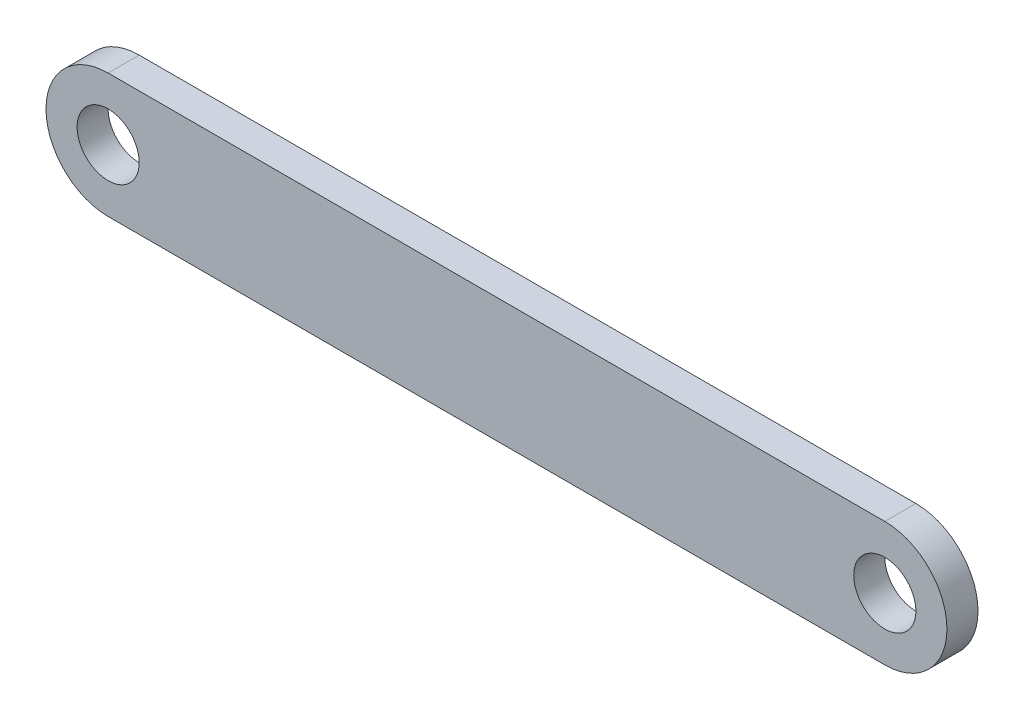
from build123d import *

# Parameters (mm, degrees)
SKETCH2_R           = 2
BOSS_EXTRUDE1_DEPTH = 2


with BuildPart() as part:
    # Sketch2 → Boss-Extrude1 (new body)
    with BuildSketch(Plane.XY):
        with BuildLine():
            Line((0, -4), (-50, -4))
            ThreePointArc((-50, -4), (-54, 0), (-50, 4))
            Line((-50, 4), (0, 4))
            ThreePointArc((0, 4), (4, 0), (0, -4))
        make_face()
        with Locations((-50, 0)):
            Circle(SKETCH2_R, mode=Mode.SUBTRACT)
        Circle(SKETCH2_R, mode=Mode.SUBTRACT)
    extrude(amount=BOSS_EXTRUDE1_DEPTH)


solid = part.part
